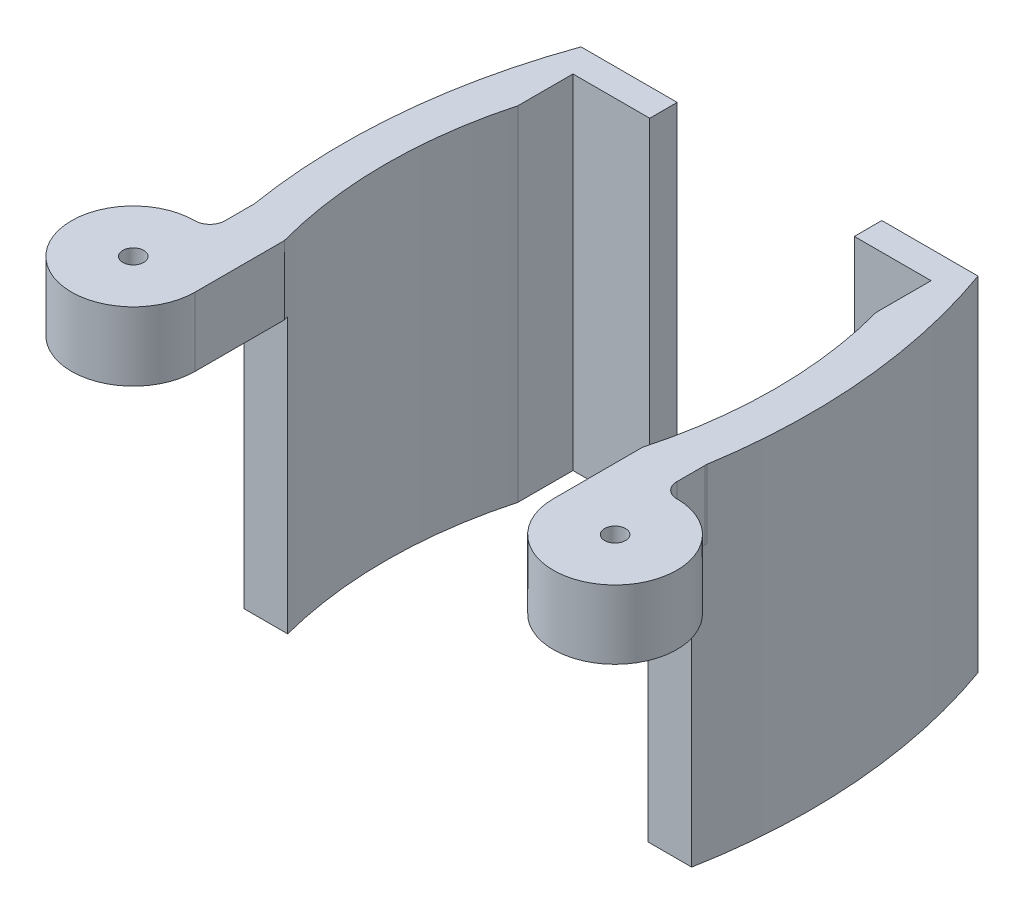
from build123d import *

# Parameters (mm, degrees)
BOSS_EXTRUDE1_DEPTH   = 50
BOSS_EXTRUDE1_2_DEPTH = 50
SKETCH2_R             = 9
CUT_EXTRUDE1_DEPTH    = 40
CUT_EXTRUDE2_DEPTH    = 40
BOSS_EXTRUDE2_DEPTH   = 10
SKETCH5_R             = 1.525
CUT_EXTRUDE3_DEPTH    = 10
BOSS_EXTRUDE3_DEPTH   = 10
SKETCH8_R             = 1.525
BOSS_EXTRUDE4_DEPTH   = 10
CUT_EXTRUDE5_DEPTH    = 10
SKETCH10_R            = 1.525
CUT_EXTRUDE6_DEPTH    = 10


with BuildPart() as part:
    # Sketch1 → Boss-Extrude1 (new body)
    with BuildSketch(Plane(origin=(0, 0, 0), x_dir=(1, 0, 0), z_dir=(0, 1, 0))):
        with BuildLine():
            Line((-9.855511121, -63.764528812), (-9.855511121, -55.764528812))
            ThreePointArc((-9.855511121, -55.764528812), (-7.578540573, -38.764528812), (-9.855511121, -21.764528812))
            Line((-9.855511121, -21.764528812), (-9.855511121, -13.764528812))
            Line((-9.855511121, -13.764528812), (-21.025316782, -13.764528812))
            Line((-21.025316782, -13.764528812), (-21.025316782, -9.764528812))
            Line((-21.025316782, -9.764528812), (-7.025316782, -9.764528812))
            ThreePointArc((-7.025316782, -9.764528812), (-2.18156011, -32.197425329), (-3.351205363, -55.117476699))
            ThreePointArc((-3.351205363, -55.117476699), (6.336889319, -69.174646732), (-9.855511121, -63.764528812))
        make_face()
    extrude(amount=-BOSS_EXTRUDE1_DEPTH)


with BuildPart() as body_2:
    # Sketch1 → Boss-Extrude1 2 (new body)
    with BuildSketch(Plane(origin=(0, 0, 0), x_dir=(1, 0, 0), z_dir=(0, 1, 0))):
        with BuildLine():
            Line((-50.810057702, -9.764528812), (-64.810057702, -9.764528812))
            ThreePointArc((-64.810057702, -9.764528812), (-69.653814374, -32.197425329), (-68.484169121, -55.117476699))
            ThreePointArc((-68.484169121, -55.117476699), (-78.172263802, -69.174646732), (-61.979863362, -63.764528812))
            Line((-61.979863362, -63.764528812), (-61.979863362, -55.764528812))
            ThreePointArc((-61.979863362, -55.764528812), (-64.256833911, -38.764528812), (-61.979863362, -21.764528812))
            Line((-61.979863362, -21.764528812), (-61.979863362, -13.764528812))
            Line((-61.979863362, -13.764528812), (-50.810057702, -13.764528812))
            Line((-50.810057702, -13.764528812), (-50.810057702, -9.764528812))
        make_face()
    extrude(amount=-BOSS_EXTRUDE1_2_DEPTH)


with BuildPart() as cut_extrude1_tool:
    # Sketch2 → Cut-Extrude1 (new body)
    with BuildSketch(Plane.XZ.offset(50)):
        with Locations((-70.979863362, 63.764528812)):
            Circle(SKETCH2_R)
        with Locations((-0.855511121, 63.764528812)):
            Circle(SKETCH2_R)
    extrude(amount=-CUT_EXTRUDE1_DEPTH)


with BuildPart() as part_1:
    add(part.part)

    # Cut-Extrude1: cut by cut_extrude1_tool
    add(cut_extrude1_tool.part, mode=Mode.SUBTRACT)


with BuildPart() as body_2_1:
    add(body_2.part)

    # Cut-Extrude1: cut by cut_extrude1_tool
    add(cut_extrude1_tool.part, mode=Mode.SUBTRACT)


with BuildPart() as cut_extrude2_tool:
    # Sketch3 → Cut-Extrude2 (new body)
    with BuildSketch(Plane.XZ.offset(50)):
        Polygon((-68.484169121, 55.117476699), (-62.152762542, 55.117476699), (-3.351205363, 55.117476699), (-3.351205363, 65.102133375), (-68.484169121, 65.102133375), align=None)
    extrude(amount=-CUT_EXTRUDE2_DEPTH)


with BuildPart() as part_2:
    add(part_1.part)

    # Cut-Extrude2: cut by cut_extrude2_tool
    add(cut_extrude2_tool.part, mode=Mode.SUBTRACT)



with BuildPart() as body_2_2:
    add(body_2_1.part)

    # Cut-Extrude2: cut by cut_extrude2_tool
    add(cut_extrude2_tool.part, mode=Mode.SUBTRACT)


with BuildPart() as part_3:
    add(part_2.part)

    add(body_2_2.part)  # Boss-Extrude2 merges body 2
    # Sketch4 → Boss-Extrude2 (add)
    with BuildSketch(Plane(origin=(0, 0, 0), x_dir=(1, 0, 0), z_dir=(0, 1, 0))):
        with BuildLine():
            Line((-68.80061851, -53.298361428), (-66.667189119, -54.389414211))
            Line((-66.667189119, -54.389414211), (-69.130149729, -56.574087603))
            Line((-69.130149729, -56.574087603), (-70.193770041, -54.798924689))
            ThreePointArc((-70.193770041, -54.798924689), (-69.130149729, -54.389414211), (-68.80061851, -53.298361428))
        make_face()
        with BuildLine():
            Line((-3.022233862, -53.234325611), (-4.829856794, -54.317394917))
            Line((-4.829856794, -54.317394917), (-2.828145338, -56.574087603))
            Line((-2.828145338, -56.574087603), (-1.517471846, -54.788905825))
            ThreePointArc((-1.517471846, -54.788905825), (-2.633556106, -54.363663707), (-3.022233862, -53.234325611))
        make_face()
    extrude(amount=-BOSS_EXTRUDE2_DEPTH)

    # Sketch5 → Cut-Extrude3 (cut)
    with BuildSketch(Plane(origin=(0, 0, 0), x_dir=(1, 0, 0), z_dir=(0, 1, 0))):
        with Locations((-70.979863362, -63.764528812)):
            Circle(SKETCH5_R)
        with Locations((-0.855511121, -63.764528812)):
            Circle(SKETCH5_R)
    extrude(amount=-CUT_EXTRUDE3_DEPTH, mode=Mode.SUBTRACT)

    # Sketch7 → Boss-Extrude3 (add)
    with BuildSketch(Plane(origin=(0, 0, 0), x_dir=(1, 0, 0), z_dir=(0, 1, 0))):
        with BuildLine():
            Line((-9.855511121, -63.764528812), (-9.855511121, -68.764528812))
            ThreePointArc((-9.855511121, -68.764528812), (-0.855511121, -77.764528812), (8.144488879, -68.764528812))
            Line((8.144488879, -68.764528812), (8.144488879, -63.764528812))
            ThreePointArc((8.144488879, -63.764528812), (-0.855511121, -72.764528812), (-9.855511121, -63.764528812))
        make_face()
        with BuildLine():
            Line((-61.979863362, -68.764528812), (-61.979863362, -63.764528812))
            ThreePointArc((-61.979863362, -63.764528812), (-70.979863362, -72.764528812), (-79.979863362, -63.764528812))
            Line((-79.979863362, -63.764528812), (-79.979863362, -68.764528812))
            ThreePointArc((-79.979863362, -68.764528812), (-70.979863362, -77.764528812), (-61.979863362, -68.764528812))
        make_face()
    extrude(amount=-BOSS_EXTRUDE3_DEPTH)

    # Sketch8 → Boss-Extrude4 (add)
    with BuildSketch(Plane(origin=(0, 0, 0), x_dir=(1, 0, 0), z_dir=(0, 1, 0))):
        with Locations((-70.979863362, -63.764528812)):
            Circle(SKETCH8_R)
        with Locations((-0.855511121, -63.764528812)):
            Circle(SKETCH8_R)
    extrude(amount=-BOSS_EXTRUDE4_DEPTH)

    # Sketch9 → Cut-Extrude5 (cut)
    with BuildSketch(Plane(origin=(0, 0, 0), x_dir=(1, 0, 0), z_dir=(0, 1, 0))):
        with BuildLine():
            Line((-68.80061851, -57.610412769), (-68.80061851, -53.298361428))
            Line((-68.80061851, -53.298361428), (-79.979863362, -53.298361428))
            Line((-79.979863362, -53.298361428), (-79.979863362, -68.764528812))
            ThreePointArc((-79.979863362, -68.764528812), (-77.33935677, -62.402350031), (-70.969828212, -59.779622471))
            ThreePointArc((-70.969828212, -59.779622471), (-69.435965322, -59.144275659), (-68.80061851, -57.610412769))
        make_face()
        with BuildLine():
            Line((-3.024563926, -53.509227684), (-3.024563926, -57.595476008))
            ThreePointArc((-3.024563926, -57.595476008), (-2.389263068, -59.129227954), (-0.855511121, -59.764528812))
            ThreePointArc((-0.855511121, -59.764528812), (5.508449909, -62.400567781), (8.144488879, -68.764528812))
            Line((8.144488879, -68.764528812), (8.144488879, -63.764528812))
            ThreePointArc((8.144488879, -63.764528812), (5.269942065, -57.170681433), (-1.517471846, -54.788905825))
            ThreePointArc((-1.517471846, -54.788905825), (-2.533126576, -54.457755259), (-3.024563926, -53.509227684))
        make_face()
        with BuildLine():
            Line((-3.024563926, -53.258097146), (-3.024563926, -53.509227684))
            ThreePointArc((-3.024563926, -53.509227684), (-2.533126576, -54.457755259), (-1.517471846, -54.788905825))
            ThreePointArc((-1.517471846, -54.788905825), (5.269942065, -57.170681433), (8.144488879, -63.764528812))
            Line((8.144488879, -63.764528812), (8.144488879, -53.235721709))
            Line((8.144488879, -53.235721709), (-3.02238196, -53.235721709))
            ThreePointArc((-3.02238196, -53.235721709), (-3.023517569, -53.246905076), (-3.024563926, -53.258097146))
        make_face()
    extrude(amount=-CUT_EXTRUDE5_DEPTH, mode=Mode.SUBTRACT)

    # Sketch10 → Cut-Extrude6 (cut)
    with BuildSketch(Plane(origin=(0, 0, 0), x_dir=(1, 0, 0), z_dir=(0, 1, 0))):
        with Locations((-70.979863362, -68.764528812)):
            Circle(SKETCH10_R)
        with Locations((-0.855511121, -68.764528812)):
            Circle(SKETCH10_R)
    extrude(amount=-CUT_EXTRUDE6_DEPTH, mode=Mode.SUBTRACT)


solid = part_3.part
